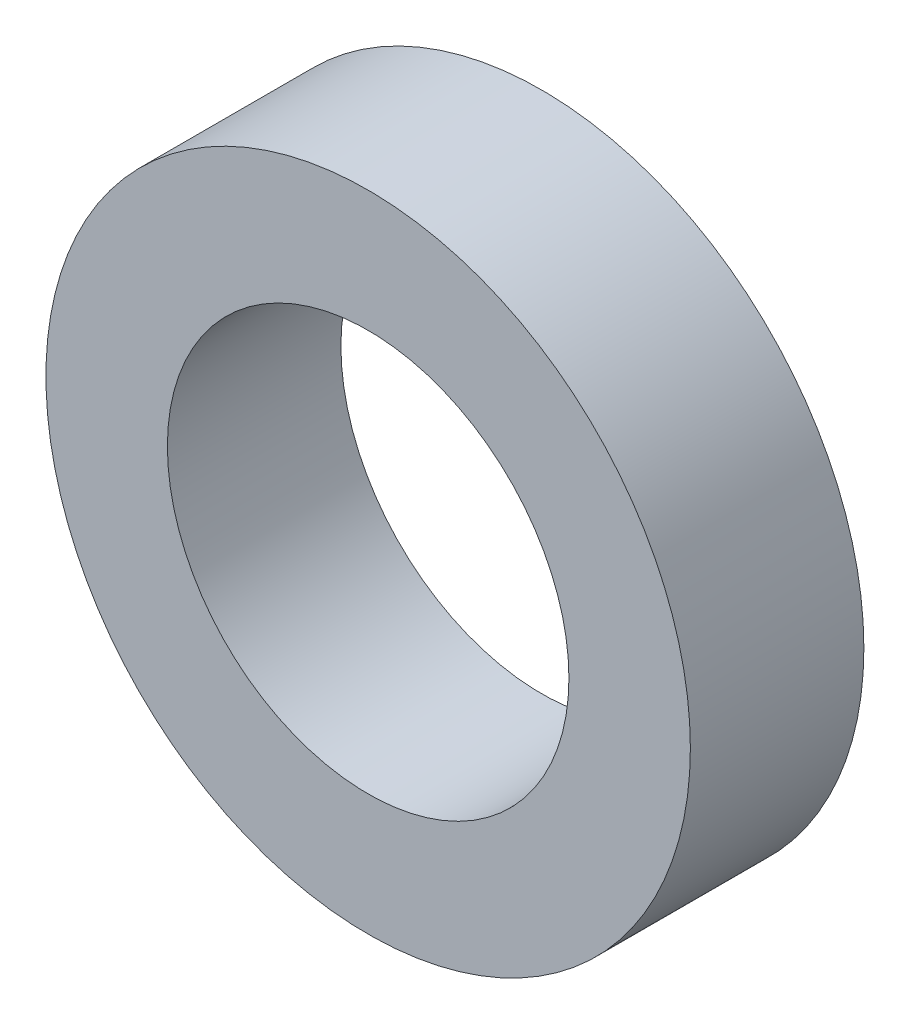
from build123d import *

# Parameters (mm, degrees)
SKETCH_1_R      = 13
SKETCH_1_R_2    = 8.1
EXTRUDE_1_DEPTH = 7


with BuildPart() as part:
    # 草图1 → 凸台-拉伸1 (new body)
    with BuildSketch(Plane.XY):
        Circle(SKETCH_1_R)
        Circle(SKETCH_1_R_2, mode=Mode.SUBTRACT)
    extrude(amount=EXTRUDE_1_DEPTH)


solid = part.part
